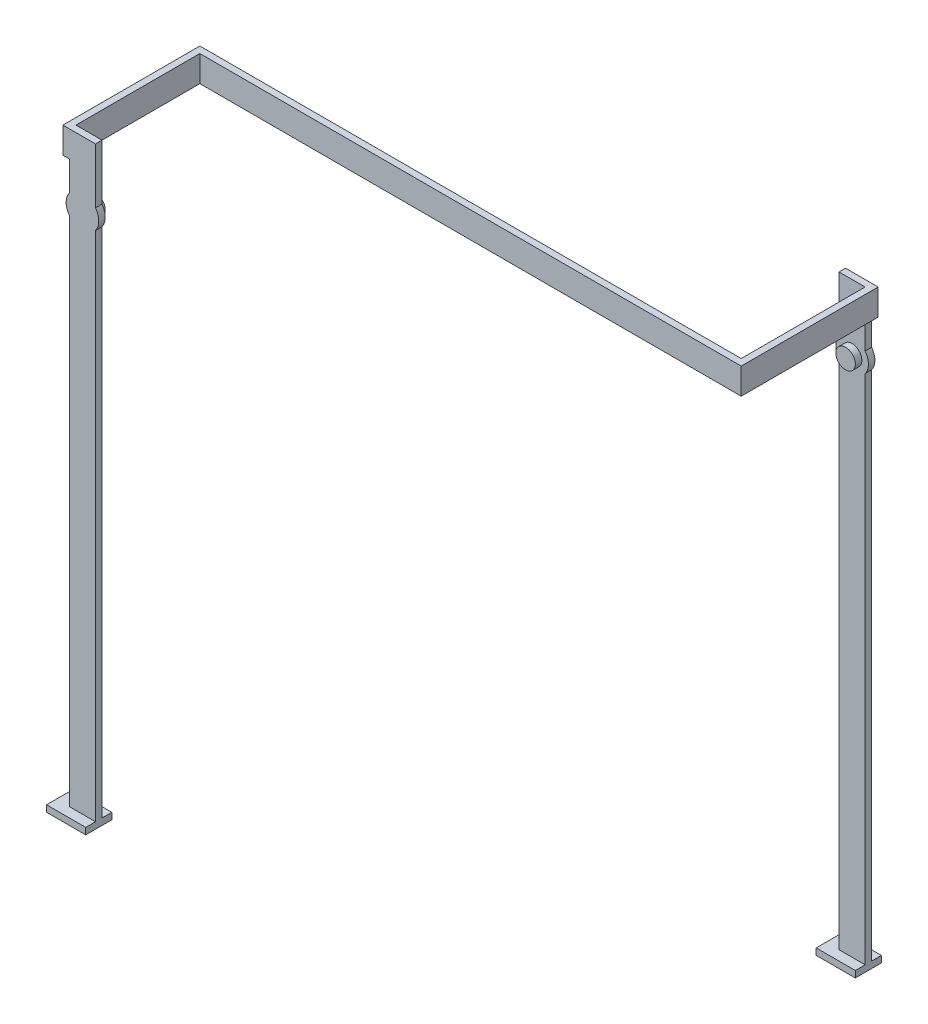
from build123d import *

# Parameters (mm, degrees)
EXTRUDE_1_DEPTH = 1
SKETCH_2_R      = 1.5
EXTRUDE_2_DEPTH = 1
EXTRUDE_3_DEPTH = 1
SKETCH_4_R      = 1.5
EXTRUDE_5_DEPTH = 1
SKETCH_5_W      = 82
SKETCH_5_H      = 4
EXTRUDE_6_DEPTH = 0.5
SKETCH_6_W      = 21
SKETCH_6_H      = 4
EXTRUDE_7_DEPTH = 1
SKETCH_7_W      = 21
SKETCH_7_H      = 4
EXTRUDE_8_DEPTH = 1
SKETCH_8_W      = 6
SKETCH_8_H      = 4
EXTRUDE_9_DEPTH = 1


with BuildPart() as part:
    # 草图1 → 凸台-拉伸1 (new body)
    with BuildSketch(Plane(origin=(0, 0, -19.5), x_dir=(-1, 0, 0), z_dir=(0, 0, -1))):
        with BuildLine():
            Line((-21.722283328, 40.092812976), (-21.722283328, -38.407187024))
            Line((-21.722283328, -38.407187024), (-25.722283328, -38.407187024))
            Line((-25.722283328, -38.407187024), (-25.722283328, 40.092812976))
            ThreePointArc((-25.722283328, 40.092812976), (-26.222283328, 41.592812976), (-25.722283328, 43.092812976))
            Line((-25.722283328, 43.092812976), (-25.722283328, 51.592812976))
            Line((-25.722283328, 51.592812976), (-21.722283328, 51.592812976))
            Line((-21.722283328, 51.592812976), (-21.722283328, 43.092812976))
            ThreePointArc((-21.722283328, 43.092812976), (-21.222283328, 41.592812976), (-21.722283328, 40.092812976))
        make_face()
    extrude(amount=EXTRUDE_1_DEPTH)

    # 草图2 → 凸台-拉伸2 (add)
    with BuildSketch(Plane.XY.offset(-19.5)):
        with Locations((23.722283328, 41.592812976)):
            Circle(SKETCH_2_R)
    extrude(amount=EXTRUDE_2_DEPTH)



with BuildPart() as body_2:
    # 草图3 → 凸台-拉伸3 (new body)
    with BuildSketch(Plane.XY.offset(19.5)):
        with BuildLine():
            Line((-52.277716672, 40.092812976), (-52.277716672, -38.407187024))
            Line((-52.277716672, -38.407187024), (-56.277716672, -38.407187024))
            Line((-56.277716672, -38.407187024), (-56.277716672, 40.092812976))
            ThreePointArc((-56.277716672, 40.092812976), (-56.777716672, 41.592812976), (-56.277716672, 43.092812976))
            Line((-56.277716672, 43.092812976), (-56.277716672, 51.592812976))
            Line((-56.277716672, 51.592812976), (-52.277716672, 51.592812976))
            Line((-52.277716672, 51.592812976), (-52.277716672, 43.092812976))
            ThreePointArc((-52.277716672, 43.092812976), (-51.777716672, 41.592812976), (-52.277716672, 40.092812976))
        make_face()
    extrude(amount=EXTRUDE_3_DEPTH)

    # 草图4 → 凸台-拉伸5 (add)
    with BuildSketch(Plane(origin=(0, 0, 19.5), x_dir=(-1, 0, 0), z_dir=(0, 0, -1))):
        with Locations((54.277716672, 41.592812976)):
            Circle(SKETCH_4_R)
    extrude(amount=EXTRUDE_5_DEPTH)



with BuildPart() as body_3:
    # 草图5 → 凸台-拉伸6 (new body, symmetric)
    with BuildSketch(Plane.XY):
        with Locations((-15.277716672, 49.592812976)):
            Rectangle(SKETCH_5_W, SKETCH_5_H)
    extrude(amount=EXTRUDE_6_DEPTH, both=True)


with BuildPart() as body_2_1:
    add(body_2.part)

    add(body_3.part)  # 凸台-拉伸7 merges body 3
    # 草图6 → 凸台-拉伸7 (add)
    with BuildSketch(Plane.ZY.offset(56.277716672)):
        with Locations((10, 49.592812976)):
            Rectangle(SKETCH_6_W, SKETCH_6_H)
    extrude(amount=EXTRUDE_7_DEPTH)


with BuildPart() as part_1:
    add(part.part)

    add(body_2_1.part)  # 凸台-拉伸8 merges body 2
    # 草图7 → 凸台-拉伸8 (add)
    with BuildSketch(Plane(origin=(25.722283328, 0, 0), x_dir=(0, 0, -1), z_dir=(1, 0, 0))):
        with Locations((10, 49.592812976)):
            Rectangle(SKETCH_7_W, SKETCH_7_H)
    extrude(amount=EXTRUDE_8_DEPTH)

    # 草图8 → 凸台-拉伸9 (add)
    with BuildSketch(Plane.XZ.offset(38.407187024)):
        with Locations((-55.277716672, 20)):
            Rectangle(SKETCH_8_W, SKETCH_8_H)
        with Locations((22.722283328, -20)):
            Rectangle(SKETCH_8_W, SKETCH_8_H)
    extrude(amount=EXTRUDE_9_DEPTH)


solid = part_1.part
